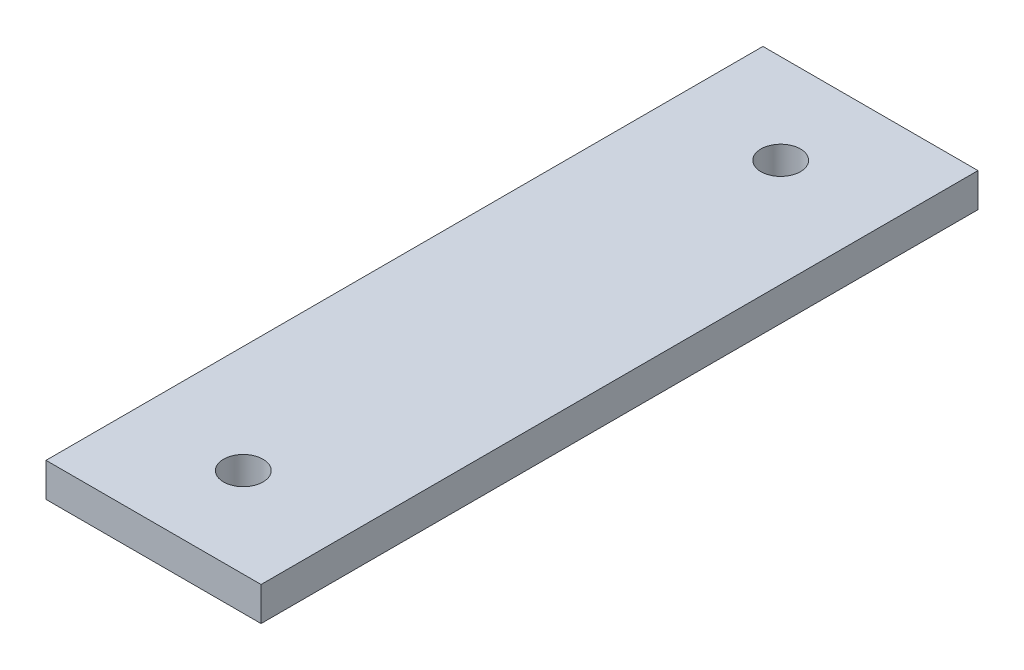
from build123d import *

# Parameters (mm, degrees)
SKETCH1_W           = 38.1
SKETCH1_H           = 127
BOSS_EXTRUDE1_DEPTH = 6
SKETCH2_R           = 3.5
CUT_EXTRUDE1_DEPTH  = 7


with BuildPart() as part:
    # Sketch1 → Boss-Extrude1 (new body)
    with BuildSketch(Plane(origin=(0, 0, 0), x_dir=(1, 0, 0), z_dir=(0, 1, 0))):
        with Locations((6.35, -38.5)):
            Rectangle(SKETCH1_W, SKETCH1_H)
    extrude(amount=BOSS_EXTRUDE1_DEPTH)

    # Sketch2 → Cut-Extrude1 (cut, through all)
    with BuildSketch(Plane(origin=(0, 6, 0), x_dir=(1, 0, 0), z_dir=(0, 1, 0))):
        with Locations((6.35, 9.1)):
            Circle(SKETCH2_R)
        with Locations((6.35, -86.1)):
            Circle(SKETCH2_R)
    extrude(amount=-CUT_EXTRUDE1_DEPTH, mode=Mode.SUBTRACT)


solid = part.part
